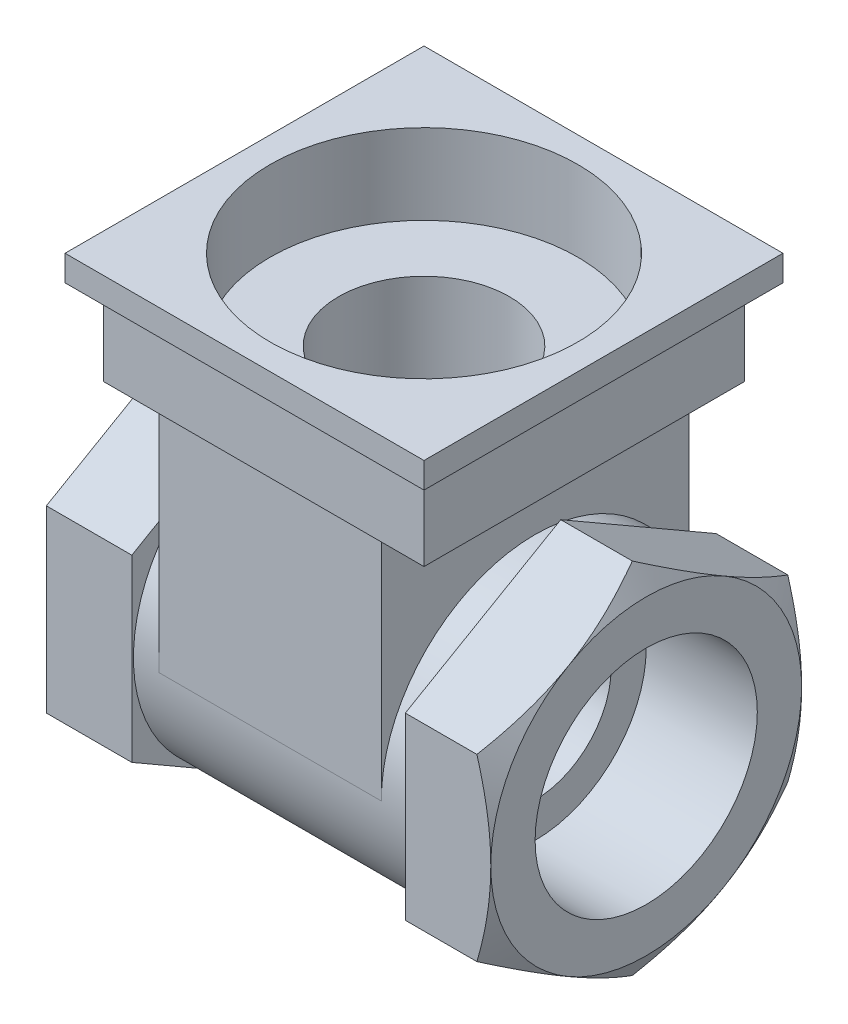
from build123d import *

# Parameters (mm, degrees)
SKETCH1_R                 = 18
BOSS_EXTRUDE1_DEPTH       = 16
BOSS_EXTRUDE2_DEPTH       = 10
BOSS_EXTRUDE6_DEPTH       = 10
SKETCH5_R                 = 13
CUT_EXTRUDE1_DEPTH        = 13
SKETCH6_R                 = 13
CUT_EXTRUDE2_DEPTH        = 13
SKETCH7_R                 = 8.9
CUT_EXTRUDE3_DEPTH        = 48.882669099
SKETCH8_OUTSIDE_W         = 70.914
SKETCH8_OUTSIDE_H         = 76.54
SKETCH8_OUTSIDE_R         = 18.186533479
CUT_EXTRUDE4_DEPTH        = 5
CUT_EXTRUDE4_DRAFT        = -60
SKETCH9_R                 = 18.186533479
CUT_EXTRUDE5_DEPTH        = 5
CUT_EXTRUDE5_DRAFT        = -60
SKETCH10_W                = 42
SKETCH10_H                = 42
BOSS_EXTRUDE8_DEPTH       = 3
SKETCH11_W                = 37.5
SKETCH11_H                = 37.5
BOSS_EXTRUDE9_DEPTH       = 13
BOSS_EXTRUDE10_REACH      = 71.556
BOSS_EXTRUDE10_END_RADIUS = 18
SKETCH12_W                = 26
SKETCH12_H                = 36


with BuildPart() as part:
    # Sketch1 → Boss-Extrude1 (new, symmetric)
    with BuildSketch(Plane(origin=(0, 0, 0), x_dir=(0, 0, -1), z_dir=(1, 0, 0))):
        Circle(SKETCH1_R)
    extrude(amount=BOSS_EXTRUDE1_DEPTH, both=True)

    # Sketch2 → Boss-Extrude2 (add)
    with BuildSketch(Plane(origin=(16, 0, 0), x_dir=(0, 0, -1), z_dir=(1, 0, 0))):
        Polygon((0, 21), (-18.186533479, 10.5), (-18.186533479, -10.5), (0, -21), (18.186533479, -10.5), (18.186533479, 10.5), align=None)
    extrude(amount=BOSS_EXTRUDE2_DEPTH)

    # Sketch4 → Boss-Extrude6 (add)
    with BuildSketch(Plane.ZY.offset(16)):
        Polygon((18.186533479, 10.5), (0, 21), (-18.186533479, 10.5), (-18.186533479, -10.5), (0, -21), (18.186533479, -10.5), align=None)
    extrude(amount=BOSS_EXTRUDE6_DEPTH)

    # Sketch5 → Cut-Extrude1 (cut)
    with BuildSketch(Plane.ZY.offset(26)):
        Circle(SKETCH5_R)
    extrude(amount=-CUT_EXTRUDE1_DEPTH, mode=Mode.SUBTRACT)

    # Sketch6 → Cut-Extrude2 (cut)
    with BuildSketch(Plane(origin=(26, 0, 0), x_dir=(0, 0, -1), z_dir=(1, 0, 0))):
        with Locations(Location((0, 0, 0), (0, 0, 180))):
            Circle(SKETCH6_R)
    extrude(amount=-CUT_EXTRUDE2_DEPTH, mode=Mode.SUBTRACT)

    # Sketch7 → Cut-Extrude3 (cut, through all)
    with BuildSketch(Plane(origin=(13, 0, 0), x_dir=(0, 0, -1), z_dir=(1, 0, 0))):
        Circle(SKETCH7_R)
    extrude(amount=-CUT_EXTRUDE3_DEPTH, mode=Mode.SUBTRACT)


with BuildPart() as cut_extrude4_tool:
    # Sketch8 outside → Cut-Extrude4 (with draft: the straight prism first)
    with BuildSketch(Plane(origin=(26, 0, 0), x_dir=(0, 0, -1), z_dir=(1, 0, 0))):
        Rectangle(SKETCH8_OUTSIDE_W, SKETCH8_OUTSIDE_H)
        Circle(SKETCH8_OUTSIDE_R, mode=Mode.SUBTRACT)
    extrude(amount=-CUT_EXTRUDE4_DEPTH)
    # Cut-Extrude4: the draft: its side faces are tilted about the plane it starts from
    cut_extrude4_sides = [cut_extrude4_tool.faces().sort_by_distance(p)[0] for p in [
        (23.5, -38.27, 0),
        (23.5, 0, -35.457),
        (23.5, 38.27, 0),
        (23.5, 0, 35.457),
        (23.5, 0, 18.186533479),
    ]]
    draft(cut_extrude4_sides, Plane(origin=(26, 0, 0), x_dir=(0, 0, -1), z_dir=(1, 0, 0)), CUT_EXTRUDE4_DRAFT)


with BuildPart() as part_1:
    add(part.part)

    # Cut-Extrude4: cut by cut_extrude4_tool
    add(cut_extrude4_tool.part, mode=Mode.SUBTRACT)


with BuildPart() as cut_extrude5_tool:
    # Sketch9 → Cut-Extrude5 (with draft: the straight prism first)
    with BuildSketch(Plane.ZY.offset(26)):
        Circle(SKETCH9_R)
    extrude(amount=-CUT_EXTRUDE5_DEPTH)
    # Cut-Extrude5: the draft: its side faces are tilted about the plane it starts from
    cut_extrude5_sides = [cut_extrude5_tool.faces().sort_by_distance(p)[0] for p in [
        (-23.5, 0, -18.186533479),
    ]]
    draft(cut_extrude5_sides, Plane.ZY.offset(26), CUT_EXTRUDE5_DRAFT)


with BuildPart() as part_2:
    add(part_1.part)

    # Cut-Extrude5: cut by cut_extrude5_tool
    add(cut_extrude5_tool.part, mode=Mode.SUBTRACT)



with BuildPart() as body_2:
    # Sketch10 → Boss-Extrude8 (new body)
    with BuildSketch(Plane(origin=(0, 40, 0), x_dir=(1, 0, 0), z_dir=(0, 1, 0))):
        Rectangle(SKETCH10_W, SKETCH10_H)
    extrude(amount=-BOSS_EXTRUDE8_DEPTH)

    # Sketch11 → Boss-Extrude9 (add)
    with BuildSketch(Plane(origin=(0, 40, 0), x_dir=(1, 0, 0), z_dir=(0, 1, 0))):
        Rectangle(SKETCH11_W, SKETCH11_H)
    extrude(amount=-BOSS_EXTRUDE9_DEPTH)


with BuildPart() as part_3:
    add(part_2.part)

    add(body_2.part)  # Boss-Extrude10 merges body 2
    # Boss-Extrude10: up to this cylinder (the profile starts outside it)
    boss_extrude10_end = Plane(origin=(0, 0, 0), z_dir=(-1, 0, 0)) * Cylinder(BOSS_EXTRUDE10_END_RADIUS, 180.112, mode=Mode.PRIVATE)
    # Sketch12 → Boss-Extrude10 (add, up to the surface)
    with BuildSketch(Plane(origin=(0, 40, 0), x_dir=(1, 0, 0), z_dir=(0, 1, 0)), mode=Mode.PRIVATE) as boss_extrude10_sk1:
        Rectangle(SKETCH12_W, SKETCH12_H)
    boss_extrude10_tool1 = extrude(boss_extrude10_sk1.sketch, amount=-BOSS_EXTRUDE10_REACH, mode=Mode.PRIVATE) - boss_extrude10_end
    add(boss_extrude10_tool1.solids().sort_by_distance((0, 40, 0))[0])

    # Sketch13 → Cut-Revolve1 (revolve, cut)
    with BuildSketch(Plane.XY, mode=Mode.PRIVATE) as cut_revolve1_sk:
        Polygon((0, 40), (0, -9.9), (7, -9.9), (9, 16.1), (10, 16.1), (10, 30.604253251), (18, 30.604253251), (18, 40), align=None)
    revolve(cut_revolve1_sk.sketch.rotate(Axis((0, 40, 0), (0, -1, 0)), 180), axis=Axis((0, 40, 0), (0, -1, 0)), mode=Mode.SUBTRACT)


solid = part_3.part
